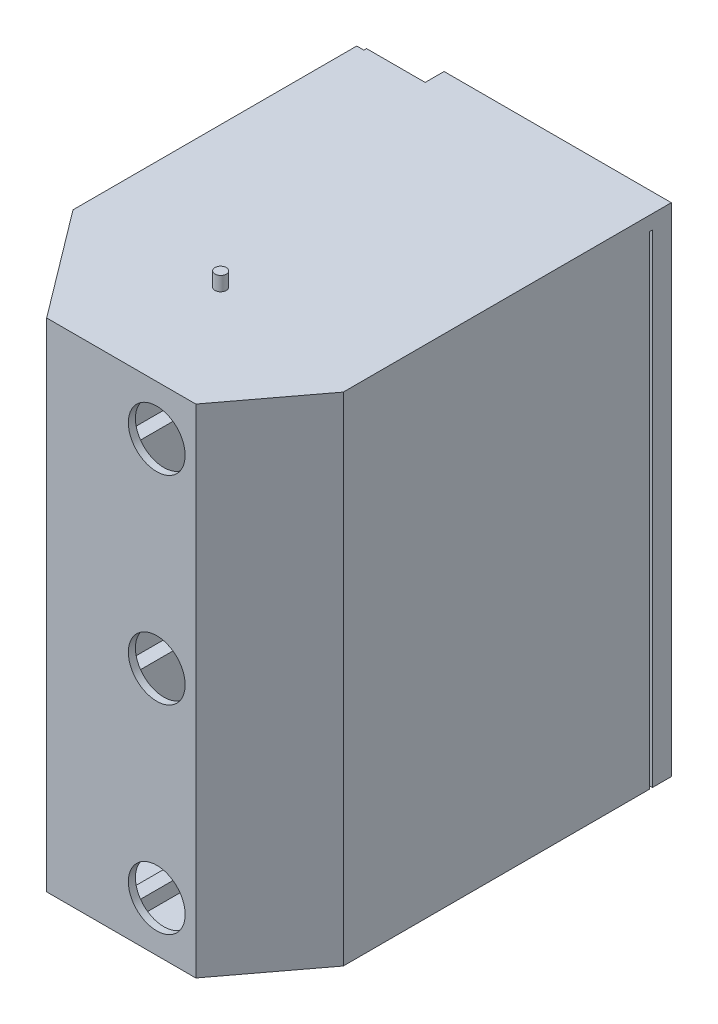
from build123d import *

# Parameters (mm, degrees)
EXTRUDE_THIN1_DEPTH       = 350
SKETCH5_W                 = 10
SKETCH5_H                 = 250
EXTRUDE_THIN3_DEPTH       = 350
SKETCH8_W                 = 150
SKETCH8_H                 = 30
CUT_EXTRUDE2_DEPTH        = 20
LPATTERN4_COUNT           = 2
LPATTERN4_PITCH           = 140
LPATTERN5_COUNT           = 2
LPATTERN5_PITCH           = 140
BOSS_EXTRUDE1_DEPTH       = 10
BOSS_EXTRUDE2_DEPTH       = 10
SKETCH12_R                = 20
CUT_EXTRUDE3_DEPTH        = 5
SKETCH13_W                = 45
SKETCH13_H                = 5
EXTRUDE_THIN4_DEPTH       = 45
BOSS_EXTRUDE4_DEPTH       = 5
LPATTERN6_COUNT           = 2
LPATTERN6_PITCH           = 140
SKETCH16_R                = 4
BOSS_EXTRUDE13_DEPTH      = 10
BOSS_EXTRUDE13_DEPTH_BACK = 380
SCALE2_SCALE              = 0.75
SKETCH18_W                = 120
SKETCH18_H                = 262.5
BOSS_EXTRUDE14_DEPTH      = 10
CUT_EXTRUDE4_DEPTH        = 1


with BuildPart() as part:
    # Sketch1 → Extrude-Thin1 (new body)
    with BuildSketch(Plane(origin=(0, 0, 0), x_dir=(1, 0, 0), z_dir=(0, 1, 0))):
        Polygon((-104.163352084, 270), (-104.163352084, 71.877195904), (-50, 0), (50, 0), (92.127051621, 55.904485703), (92.127051621, 270), (97.127051621, 270), (97.127051621, 54.231509106), (52.49290804, -5), (-52.49290804, -5), (-109.163352084, 70.204219307), (-109.163352084, 270), align=None)
    extrude(amount=EXTRUDE_THIN1_DEPTH)

    # Sketch5 → Extrude-Thin3 (add)
    with BuildSketch(Plane.XZ):
        with Locations((0, -125)):
            Rectangle(SKETCH5_W, SKETCH5_H)
    extrude(amount=-EXTRUDE_THIN3_DEPTH)

    # Sketch8 → Cut-Extrude2 (cut)
    with BuildSketch(Plane(origin=(5, 0, 0), x_dir=(0, 0, -1), z_dir=(1, 0, 0))):
        with Locations((75, 175)):
            Rectangle(SKETCH8_W, SKETCH8_H)
    cut_extrude2 = extrude(amount=-CUT_EXTRUDE2_DEPTH, mode=Mode.SUBTRACT)

    # LPattern4: Cut-Extrude2 ×2
    with Locations(*[(0, i * LPATTERN4_PITCH, 0) for i in range(1, LPATTERN4_COUNT)]):
        add(cut_extrude2, mode=Mode.SUBTRACT)

    # LPattern5: Cut-Extrude2 ×2
    with Locations(*[(0, -i * LPATTERN5_PITCH, 0) for i in range(1, LPATTERN5_COUNT)]):
        add(cut_extrude2, mode=Mode.SUBTRACT)

    # Sketch9 → Boss-Extrude1 (add)
    with BuildSketch(Plane(origin=(0, 0, 0), x_dir=(-1, 0, 0), z_dir=(0, -1, 0))):
        Polygon((104.163352084, 270), (104.163352084, 71.877195904), (50, 0), (-50, 0), (-92.127051621, 55.904485703), (-92.127051621, 270), align=None)
    extrude(amount=-BOSS_EXTRUDE1_DEPTH)

    # Sketch10 → Boss-Extrude2 (add)
    with BuildSketch(Plane(origin=(0, 350, 0), x_dir=(1, 0, 0), z_dir=(0, 1, 0))):
        Polygon((97.127051621, 271.877195904), (97.127051621, 54.231509106), (50, 0), (-50, 0), (-104.163352084, 71.877195904), (-104.163352084, 271.877195904), align=None)
    extrude(amount=-BOSS_EXTRUDE2_DEPTH)

    # Sketch12 → Cut-Extrude3 (cut)
    with BuildSketch(Plane(origin=(0, 0, 0), x_dir=(-1, 0, 0), z_dir=(0, 0, -1))):
        with Locations((-25, 35)):
            Circle(SKETCH12_R)
        with Locations((-25, 175)):
            Circle(SKETCH12_R)
        with Locations((-25, 315)):
            Circle(SKETCH12_R)
    extrude(amount=-CUT_EXTRUDE3_DEPTH, mode=Mode.SUBTRACT)

    # Sketch13 → Extrude-Thin4 (add)
    with BuildSketch(Plane(origin=(0, 0, 0), x_dir=(-1, 0, 0), z_dir=(0, 0, -1))):
        with Locations((-27.5, 107.5)):
            Rectangle(SKETCH13_W, SKETCH13_H)
    extrude_thin4 = extrude(amount=EXTRUDE_THIN4_DEPTH)

    # Sketch15 → Boss-Extrude4 (add)
    with BuildSketch(Plane(origin=(0, 110, 0), x_dir=(1, 0, 0), z_dir=(0, 1, 0))):
        Polygon((50, 0), (50, 45), (85.745079967, 45), align=None)
    boss_extrude4 = extrude(amount=-BOSS_EXTRUDE4_DEPTH)

    # LPattern6: Extrude-Thin4, Boss-Extrude4 ×2
    with Locations(*[(0, i * LPATTERN6_PITCH, 0) for i in range(1, LPATTERN6_COUNT)]):
        add(extrude_thin4)
        add(boss_extrude4)

    # Sketch16 → Boss-Extrude13 (add, two sides)
    with BuildSketch(Plane(origin=(0, 350, 0), x_dir=(1, 0, 0), z_dir=(0, 1, 0))) as boss_extrude13_sk:
        with Locations((-10, 75)):
            Circle(SKETCH16_R)
    extrude(amount=BOSS_EXTRUDE13_DEPTH)
    extrude(boss_extrude13_sk.sketch, amount=-BOSS_EXTRUDE13_DEPTH_BACK)


with BuildPart() as part_1:
    # Scale2: scaled about (-3.292238466, 175.177338181, -126.041158909)
    add(part.part.scale(SCALE2_SCALE).moved(Location((-0.823059617, 43.794334545, -31.510289727))))

    # Sketch18 → Boss-Extrude14 (add)
    with BuildSketch(Plane(origin=(0, 0, -235.418186655), x_dir=(-1, 0, 0), z_dir=(0, 0, -1))):
        with Locations((-12.022229099, 175.044334545)):
            Rectangle(SKETCH18_W, SKETCH18_H)
    extrude(amount=BOSS_EXTRUDE14_DEPTH)

    # Sketch19 → Cut-Extrude4 (cut)
    with BuildSketch(Plane(origin=(0, 0, -245.418186655), x_dir=(-1, 0, 0), z_dir=(0, 0, -1))):
        Polygon((32.977770901, 295.909719161), (32.977770901, 297.255873007), (38.689910324, 297.255873007), (32.977770901, 303.508877814), (32.977770901, 305.42894993), (39.708540132, 298.058156661), (47.977770901, 306.005873007), (47.977770901, 304.212002814), (40.73918917, 297.255873007), (47.977770901, 297.255873007), (47.977770901, 295.909719161), align=None)
        Polygon((47.977770901, 280.525103776), (32.977770901, 280.525103776), (32.977770901, 280.807555699), (44.783660324, 290.717411468), (32.977770901, 290.717411468), (32.977770901, 292.063565314), (47.977770901, 292.063565314), (47.977770901, 291.75707493), (36.198924747, 281.871257622), (47.977770901, 281.871257622), align=None)
        Polygon((32.977770901, 271.294334545), (47.977770901, 278.217411468), (47.977770901, 276.754070122), (43.170078593, 274.536522045), (43.170078593, 267.736642237), (47.977770901, 265.455993199), (47.977770901, 263.986642237), (32.977770901, 271.102026853), align=None)
        Polygon((35.901448786, 271.183156661), (41.631617055, 268.466810507), (41.631617055, 273.82738743), align=None, mode=Mode.SUBTRACT)
        Polygon((34.516232439, 254.563565314), (32.977770901, 254.563565314), (32.977770901, 262.448180699), (34.516232439, 262.448180699), (34.516232439, 259.17894993), (47.977770901, 259.17894993), (47.977770901, 257.832796084), (34.516232439, 257.832796084), align=None)
        with BuildLine():
            Line((47.977770901, 235.140488391), (32.977770901, 235.140488391))
            Line((32.977770901, 235.140488391), (32.977770901, 238.169334545))
            add(Edge.make_bspline(
                [(32.977770901, 238.169334545), (32.97966763, 238.432773066), (32.983332099, 238.941734917), (33.006566633, 239.677216835), (33.047668629, 240.357718674), (33.107538027, 240.981002356), (33.181051028, 241.548778979), (33.273195618, 242.059458728), (33.382002063, 242.515682197), (33.474768278, 242.796265514), (33.518636286, 242.92894993)],
                knots=[0, 0, 0, 0, 0.000790316, 0.001526886, 0.002207274, 0.002835157, 0.003405034, 0.003924274, 0.004391423, 0.004810516, 0.004810516, 0.004810516, 0.004810516], degree=3))
            add(Edge.make_bspline(
                [(33.518636286, 242.92894993), (33.584747287, 243.102514443), (33.715470111, 243.445707601), (33.962438944, 243.934082652), (34.241116012, 244.395399908), (34.557914451, 244.825981336), (34.908697403, 245.226907315), (35.29095888, 245.602728235), (35.713190655, 245.944178225), (36.167877255, 246.256575373), (36.649192862, 246.538317958), (37.156349206, 246.783195111), (37.686735643, 246.986570714), (38.238886715, 247.155398459), (38.814013927, 247.288454808), (39.412787673, 247.379234487), (40.032841332, 247.439110166), (40.453589035, 247.445127527), (40.667073786, 247.448180699)],
                knots=[0, 0, 0, 0, 0.000556863, 0.001101098, 0.001639102, 0.002172182, 0.002702469, 0.003235812, 0.00377831, 0.00432924, 0.004889433, 0.005449852, 0.006016798, 0.006591848, 0.007180798, 0.007785966, 0.008407584, 0.009047862, 0.009047862, 0.009047862, 0.009047862], degree=3))
            add(Edge.make_bspline(
                [(40.667073786, 247.448180699), (40.852479092, 247.445485122), (41.217839612, 247.440173206), (41.756300618, 247.392476168), (42.278787264, 247.323148973), (42.782812013, 247.215817092), (43.272788924, 247.085519169), (43.743502816, 246.918535218), (44.199246336, 246.727220917), (44.633950262, 246.50422105), (45.045526889, 246.25907132), (45.433802186, 245.997626489), (45.790160193, 245.713957188), (46.123939108, 245.416459171), (46.426222401, 245.097958314), (46.702520291, 244.762332319), (46.948206952, 244.408276852), (47.167143114, 244.033600211), (47.362931666, 243.633298493), (47.526242809, 243.194780184), (47.667686931, 242.720122457), (47.780205737, 242.206618458), (47.870952961, 241.6560997), (47.931372812, 241.067039029), (47.972348884, 240.440549691), (47.975928469, 240.010351353), (47.977770901, 239.788925891)],
                knots=[0, 0, 0, 0, 0.000556092, 0.001095838, 0.001620648, 0.002136295, 0.002640709, 0.003140574, 0.003633371, 0.004122528, 0.004604872, 0.005069919, 0.005525591, 0.005970272, 0.006410217, 0.006841509, 0.007273282, 0.007701538, 0.008142335, 0.008608322, 0.009103642, 0.009627065, 0.010184285, 0.010776598, 0.011402817, 0.012066988, 0.012066988, 0.012066988, 0.012066988], degree=3))
            Line((47.977770901, 239.788925891), (47.977770901, 235.140488391))
        make_face()
        with BuildLine():
            Line((46.439309363, 236.486642237), (46.439309363, 238.208397045))
            add(Edge.make_bspline(
                [(46.439309363, 238.208397045), (46.438246092, 238.455804348), (46.436201034, 238.931659199), (46.418255878, 239.615907758), (46.388933289, 240.241105172), (46.347897241, 240.807340212), (46.293603176, 241.314293173), (46.233067878, 241.76302353), (46.157650232, 242.152060351), (46.089288978, 242.387472224), (46.057698786, 242.496257622)],
                knots=[0, 0, 0, 0, 0.000742212, 0.001427545, 0.002053267, 0.002619735, 0.00313042, 0.003582561, 0.003977976, 0.004317679, 0.004317679, 0.004317679, 0.004317679], degree=3))
            add(Edge.make_bspline(
                [(46.057698786, 242.496257622), (46.009477831, 242.633179188), (45.914187677, 242.903751951), (45.740369, 243.293242111), (45.534474894, 243.656487175), (45.305606253, 243.999813081), (45.045701359, 244.318366244), (44.760372548, 244.615859287), (44.44831622, 244.891927991), (44.110038388, 245.142320151), (43.749207269, 245.369117821), (43.365184702, 245.563814108), (42.963369468, 245.733369068), (42.540508642, 245.86762589), (42.099701569, 245.973481512), (41.638662476, 246.047680385), (41.15779933, 246.093744167), (40.830440186, 246.099235855), (40.664068978, 246.102026853)],
                knots=[0, 0, 0, 0, 0.000435397, 0.000860394, 0.001277456, 0.001686651, 0.002096804, 0.002509088, 0.002922071, 0.003345152, 0.003770361, 0.00419905, 0.00463544, 0.005077311, 0.005528442, 0.005994275, 0.006477152, 0.006976176, 0.006976176, 0.006976176, 0.006976176], degree=3))
            add(Edge.make_bspline(
                [(40.664068978, 246.102026853), (40.488639777, 246.09982705), (40.144007558, 246.095505517), (39.63833315, 246.041187044), (39.151987504, 245.961808949), (38.684938096, 245.847021723), (38.236273729, 245.700746528), (37.808475828, 245.518198064), (37.39702639, 245.309626838), (37.011421966, 245.06146968), (36.646737212, 244.789688566), (36.312644717, 244.488069083), (36.00838343, 244.161403204), (35.729214947, 243.813253849), (35.486370622, 243.433809138), (35.269141989, 243.032007606), (35.084788169, 242.601954729), (34.9867359, 242.302757461), (34.936905516, 242.150704737)],
                knots=[0, 0, 0, 0, 0.000526056, 0.001033442, 0.001523971, 0.002003509, 0.002474814, 0.002938022, 0.00339763, 0.003856933, 0.004311862, 0.004760786, 0.005205102, 0.005649976, 0.006097541, 0.006554627, 0.007019013, 0.00749889, 0.00749889, 0.00749889, 0.00749889], degree=3))
            add(Edge.make_bspline(
                [(34.936905516, 242.150704737), (34.902120825, 242.02491411), (34.828159029, 241.757448723), (34.747478861, 241.320993877), (34.676316722, 240.829786094), (34.616067982, 240.281644518), (34.572836605, 239.677193979), (34.540388114, 239.015969602), (34.518502546, 238.297685582), (34.517008087, 237.799760437), (34.516232439, 237.541329737)],
                knots=[0, 0, 0, 0, 0.000391375, 0.000832172, 0.001330209, 0.001880376, 0.002486022, 0.003147905, 0.003866362, 0.004641626, 0.004641626, 0.004641626, 0.004641626], degree=3))
            Line((34.516232439, 237.541329737), (34.516232439, 236.486642237))
            Line((34.516232439, 236.486642237), (46.439309363, 236.486642237))
        make_face(mode=Mode.SUBTRACT)
        Polygon((32.977770901, 223.986642237), (32.977770901, 232.448180699), (34.516232439, 232.448180699), (34.516232439, 225.332796084), (39.131617055, 225.332796084), (39.131617055, 232.448180699), (40.670078593, 232.448180699), (40.670078593, 225.332796084), (46.439309363, 225.332796084), (46.439309363, 232.448180699), (47.977770901, 232.448180699), (47.977770901, 223.986642237), align=None)
        Polygon((32.977770901, 212.832796084), (32.977770901, 221.294334545), (34.516232439, 221.294334545), (34.516232439, 214.17894993), (39.131617055, 214.17894993), (39.131617055, 221.294334545), (40.670078593, 221.294334545), (40.670078593, 214.17894993), (46.439309363, 214.17894993), (46.439309363, 221.294334545), (47.977770901, 221.294334545), (47.977770901, 212.832796084), align=None)
        with BuildLine():
            Line((45.084141093, 200.909719161), (44.323924747, 202.177748007))
            add(Edge.make_bspline(
                [(44.323924747, 202.177748007), (44.52134354, 202.295683309), (44.899590328, 202.521642798), (45.410696215, 202.898577194), (45.845105459, 203.289146813), (46.20029092, 203.696243957), (46.479929006, 204.117383735), (46.67793857, 204.555315394), (46.801435607, 205.008563154), (46.816435978, 205.317022389), (46.823924747, 205.471017237)],
                knots=[0, 0, 0, 0, 0.000689576, 0.0013212, 0.001901906, 0.0024387, 0.002937914, 0.003412645, 0.003875444, 0.004336836, 0.004336836, 0.004336836, 0.004336836], degree=3))
            add(Edge.make_bspline(
                [(46.823924747, 205.471017237), (46.820174723, 205.602505729), (46.812740292, 205.863181972), (46.744191144, 206.24769154), (46.632044879, 206.619258727), (46.480018476, 206.974189922), (46.293144974, 207.303081773), (46.072786045, 207.59611279), (45.81816919, 207.843546416), (45.538726761, 208.048671885), (45.239070758, 208.207396482), (44.930317812, 208.327362075), (44.608231601, 208.394549268), (44.391320931, 208.40463129), (44.281857439, 208.409719161)],
                knots=[0, 0, 0, 0, 0.000394191, 0.000781485, 0.001167436, 0.001556463, 0.001937363, 0.002299751, 0.00265248, 0.00299866, 0.003336082, 0.003667021, 0.003989377, 0.004317782, 0.004317782, 0.004317782, 0.004317782], degree=3))
            add(Edge.make_bspline(
                [(44.281857439, 208.409719161), (44.156926399, 208.403536393), (43.90392742, 208.391015615), (43.53001849, 208.280669169), (43.15839451, 208.112174763), (42.928477841, 207.953808958), (42.80950167, 207.871858584)],
                knots=[0, 0, 0, 0, 0.000374059, 0.000757511, 0.001160872, 0.00159345, 0.00159345, 0.00159345, 0.00159345], degree=3))
            add(Edge.make_bspline(
                [(42.80950167, 207.871858584), (42.72357585, 207.804708654), (42.543185337, 207.663735776), (42.274896485, 207.421173563), (41.997596006, 207.137992392), (41.70519618, 206.818068049), (41.400125641, 206.460863885), (41.080003775, 206.066241697), (40.751372303, 205.630833612), (40.531252791, 205.325222145), (40.417674747, 205.167531661)],
                knots=[0, 0, 0, 0, 0.000327083, 0.000686669, 0.001083997, 0.001515739, 0.00198669, 0.002493042, 0.003039925, 0.003622928, 0.003622928, 0.003622928, 0.003622928], degree=3))
            add(Edge.make_bspline(
                [(40.417674747, 205.167531661), (40.305266514, 205.009714534), (40.090350533, 204.707980206), (39.771389316, 204.286014853), (39.479772732, 203.90868144), (39.212755538, 203.577657084), (38.970301517, 203.293087383), (38.754738921, 203.052729907), (38.560237946, 202.862707519), (38.434060767, 202.757040745), (38.377410324, 202.709598968)],
                knots=[0, 0, 0, 0, 0.000581242, 0.00111129, 0.001586715, 0.002011882, 0.002387014, 0.002708191, 0.002980189, 0.003201812, 0.003201812, 0.003201812, 0.003201812], degree=3))
            add(Edge.make_bspline(
                [(38.377410324, 202.709598968), (38.289115783, 202.643299175), (38.115472719, 202.512911732), (37.844142926, 202.34061333), (37.56692113, 202.195313618), (37.282802616, 202.078374515), (36.993922705, 201.983810293), (36.6981126, 201.918063899), (36.397380435, 201.877539213), (36.195043866, 201.873353128), (36.093756478, 201.871257622)],
                knots=[0, 0, 0, 0, 0.000331157, 0.000651264, 0.00096307, 0.001268867, 0.001571995, 0.001873795, 0.002176804, 0.002480528, 0.002480528, 0.002480528, 0.002480528], degree=3))
            add(Edge.make_bspline(
                [(36.093756478, 201.871257622), (35.935057134, 201.876851126), (35.621050532, 201.887918576), (35.162351475, 201.981524406), (34.72439291, 202.129251914), (34.311611638, 202.336280579), (33.934378892, 202.602908656), (33.58929922, 202.912805338), (33.295241135, 203.278491863), (33.042320287, 203.683334032), (32.842309316, 204.124137313), (32.697360668, 204.588207315), (32.611262993, 205.072208153), (32.599250648, 205.400562329), (32.593155516, 205.567171084)],
                knots=[0, 0, 0, 0, 0.00047571, 0.000941251, 0.001398308, 0.00185923, 0.002321033, 0.002780464, 0.003246006, 0.00372377, 0.004209193, 0.00469389, 0.005179006, 0.005678708, 0.005678708, 0.005678708, 0.005678708], degree=3))
            add(Edge.make_bspline(
                [(32.593155516, 205.567171084), (32.599169383, 205.743960134), (32.611129044, 206.095537131), (32.717703107, 206.611861644), (32.887320552, 207.111008556), (33.086326252, 207.510759586), (33.283820254, 207.824287016), (33.464097151, 208.063151716), (33.671209825, 208.306521078), (33.909524532, 208.551779612), (34.174274737, 208.801348527), (34.467701571, 209.054078251), (34.78716078, 209.3123339), (35.015275538, 209.478421109), (35.132218016, 209.563565314)],
                knots=[0, 0, 0, 0, 0.000529878, 0.001053758, 0.001574484, 0.00210797, 0.0023889, 0.002685175, 0.003004901, 0.00334704, 0.003710522, 0.004096087, 0.004508579, 0.00494248, 0.00494248, 0.00494248, 0.00494248], degree=3))
            Line((35.132218016, 209.563565314), (36.054693978, 208.346618199))
            add(Edge.make_bspline(
                [(36.054693978, 208.346618199), (35.960022683, 208.273140989), (35.777707905, 208.131641061), (35.522475143, 207.916729139), (35.289014705, 207.714476422), (35.086769447, 207.513683708), (34.900594452, 207.329828046), (34.744027312, 207.148215863), (34.612121249, 206.975855598), (34.471096114, 206.759117328), (34.335531175, 206.484559589), (34.216453312, 206.142779389), (34.145809968, 205.784397986), (34.136387233, 205.540434888), (34.131617055, 205.416930699)],
                knots=[0, 0, 0, 0, 0.000359473, 0.000692262, 0.001000939, 0.001285683, 0.001547032, 0.001785607, 0.002004361, 0.002197722, 0.002560545, 0.002919743, 0.003280982, 0.003651355, 0.003651355, 0.003651355, 0.003651355], degree=3))
            add(Edge.make_bspline(
                [(34.131617055, 205.416930699), (34.136725022, 205.261937607), (34.146575256, 204.963048029), (34.256985429, 204.539700925), (34.424856658, 204.15646615), (34.66692522, 203.827973628), (34.955517572, 203.556742446), (35.284636824, 203.358109462), (35.648136232, 203.239350292), (35.90158045, 203.224814376), (36.030655516, 203.217411468)],
                knots=[0, 0, 0, 0, 0.000463919, 0.000894625, 0.001303455, 0.001712153, 0.002109754, 0.002484392, 0.002856892, 0.003243486, 0.003243486, 0.003243486, 0.003243486], degree=3))
            add(Edge.make_bspline(
                [(36.030655516, 203.217411468), (36.111000567, 203.219192546), (36.272809908, 203.222779513), (36.510731804, 203.268615151), (36.747399214, 203.3305887), (36.981979192, 203.425597121), (37.219783645, 203.557904215), (37.464171368, 203.731462786), (37.717247376, 203.950102129), (37.881850819, 204.117573408), (37.968756478, 204.205993199)],
                knots=[0, 0, 0, 0, 0.000240685, 0.000484723, 0.000724543, 0.00097396, 0.001241591, 0.001539203, 0.001871639, 0.002243471, 0.002243471, 0.002243471, 0.002243471], degree=3))
            add(Edge.make_bspline(
                [(37.968756478, 204.205993199), (37.998058017, 204.238827652), (38.067671767, 204.316834797), (38.181638684, 204.459445907), (38.322221994, 204.647772186), (38.496167636, 204.876895905), (38.697945331, 205.151041741), (38.924975097, 205.470239839), (39.184627064, 205.830932122), (39.366159381, 206.08688319), (39.462145901, 206.222219161)],
                knots=[0, 0, 0, 0, 0.000132007, 0.000313617, 0.000547394, 0.000837058, 0.001176615, 0.001568532, 0.002012146, 0.002509902, 0.002509902, 0.002509902, 0.002509902], degree=3))
            add(Edge.make_bspline(
                [(39.462145901, 206.222219161), (39.580608954, 206.385015817), (39.809996238, 206.700248979), (40.154633735, 207.148783018), (40.491699477, 207.555465446), (40.819019058, 207.921754189), (41.13418282, 208.25116714), (41.440738125, 208.540383625), (41.736674625, 208.79071589), (42.113503572, 209.063896971), (42.580596845, 209.339728881), (43.153132166, 209.576232073), (43.727310485, 209.726691355), (44.112728639, 209.746231864), (44.302891093, 209.755873007)],
                knots=[0, 0, 0, 0, 0.000603996, 0.001169555, 0.001696631, 0.002188218, 0.002642988, 0.003063875, 0.003452066, 0.003804872, 0.004459368, 0.005073739, 0.005658944, 0.006228884, 0.006228884, 0.006228884, 0.006228884], degree=3))
            add(Edge.make_bspline(
                [(44.302891093, 209.755873007), (44.437368376, 209.75305383), (44.703711484, 209.747470223), (45.094825386, 209.683393762), (45.474594928, 209.589297102), (45.837950262, 209.448614771), (46.190721521, 209.274106788), (46.526263181, 209.055847548), (46.851094093, 208.801534221), (47.156107562, 208.509956196), (47.436454237, 208.191066177), (47.684804979, 207.852808246), (47.896650153, 207.498713508), (48.06536406, 207.124947358), (48.198206136, 206.735525035), (48.294187357, 206.329162368), (48.353160462, 205.905447718), (48.359276679, 205.617444027), (48.362386286, 205.471017237)],
                knots=[0, 0, 0, 0, 0.000403048, 0.000798268, 0.001185982, 0.001574951, 0.00196465, 0.00236473, 0.002773483, 0.003200684, 0.003628645, 0.00404574, 0.004458001, 0.004864095, 0.005273643, 0.005690532, 0.006115062, 0.006554134, 0.006554134, 0.006554134, 0.006554134], degree=3))
            add(Edge.make_bspline(
                [(48.362386286, 205.471017237), (48.360195507, 205.357722911), (48.355841541, 205.132561083), (48.317350343, 204.799520441), (48.262891313, 204.473207933), (48.176431065, 204.157718091), (48.071529541, 203.848986555), (47.94236599, 203.548354692), (47.787575211, 203.255681997), (47.610607183, 202.969308445), (47.404603985, 202.690039126), (47.164882762, 202.420190623), (46.897556336, 202.152663973), (46.598494971, 201.889356921), (46.264410026, 201.636013996), (45.900277833, 201.386553246), (45.505015544, 201.142190408), (45.227052927, 200.988656934), (45.084141093, 200.909719161)],
                knots=[0, 0, 0, 0, 0.000339756, 0.000675233, 0.001004736, 0.001331266, 0.001655298, 0.001982381, 0.002311678, 0.002647706, 0.002991465, 0.003351302, 0.003729502, 0.004125522, 0.004545615, 0.004986514, 0.005449312, 0.00593905, 0.00593905, 0.00593905, 0.00593905], degree=3))
        make_face()
    extrude(amount=-CUT_EXTRUDE4_DEPTH, mode=Mode.SUBTRACT)


solid = part_1.part
